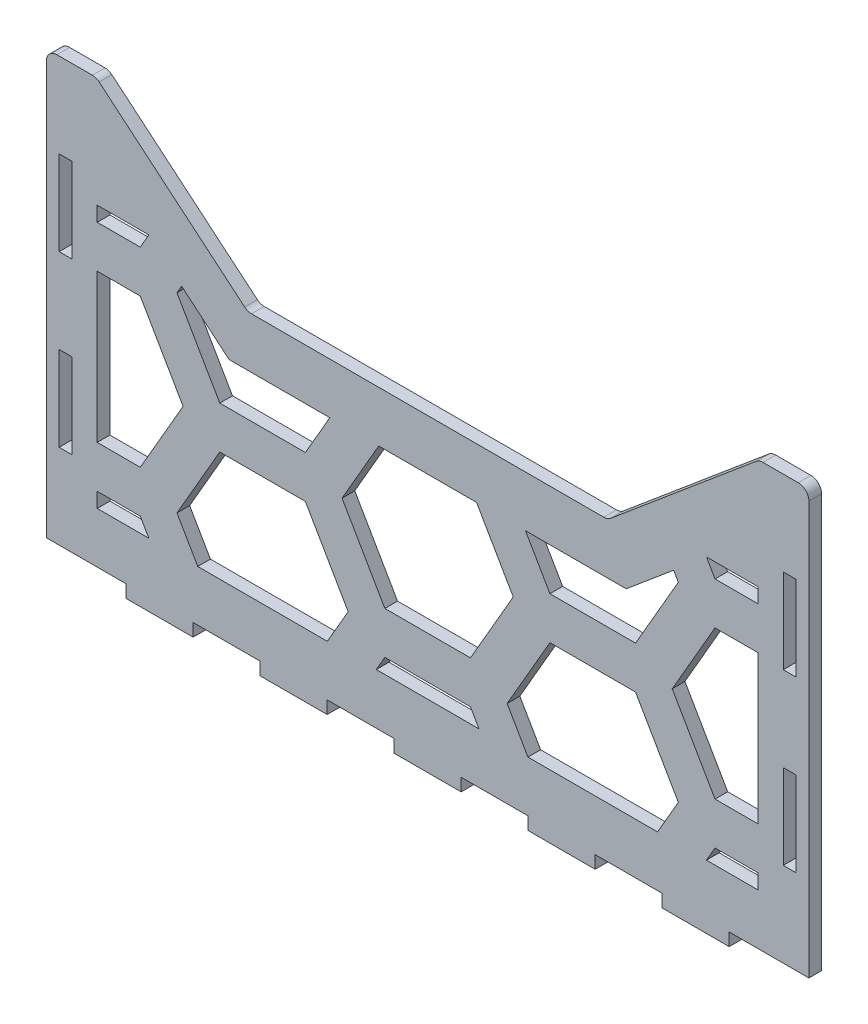
from build123d import *

# Parameters (mm, degrees)
SKETCH1_W               = 3.05
SKETCH1_H               = 20
SKETCH1_W_2             = 15.818181818
SKETCH1_H_2             = 3
BOSS_EXTRUDE1_DEPTH     = 3
CUT_EXTRUDE9_DEPTH      = 1
CUT_EXTRUDE9_DEPTH_BACK = 4
FILLET3_R               = 2.5
CUT_EXTRUDE8_DEPTH      = 4
CUT_EXTRUDE8_DEPTH_BACK = 1


with BuildPart() as part:
    # Sketch1 → Boss-Extrude1 (new body)
    with BuildSketch(Plane.XY):
        Polygon((-90, 50), (-90, -50), (-71.181818182, -50), (-55.363636364, -50), (-39.545454545, -50), (-23.727272727, -50), (-7.909090909, -50), (7.909090909, -50), (23.727272727, -50), (39.545454545, -50), (55.363636364, -50), (71.181818182, -50), (90, -50), (90, 50), align=None)
        with Locations((-85.475, -20)):
            Rectangle(SKETCH1_W, SKETCH1_H, mode=Mode.SUBTRACT)
        with Locations((85.475, -20)):
            Rectangle(SKETCH1_W, SKETCH1_H, mode=Mode.SUBTRACT)
        with Locations((-85.475, 20)):
            Rectangle(SKETCH1_W, SKETCH1_H, mode=Mode.SUBTRACT)
        with Locations((85.475, 20)):
            Rectangle(SKETCH1_W, SKETCH1_H, mode=Mode.SUBTRACT)
        with Locations((-63.272727273, -51.5)):
            Rectangle(SKETCH1_W_2, SKETCH1_H_2)
        with Locations((-31.636363636, -51.5)):
            Rectangle(SKETCH1_W_2, SKETCH1_H_2)
        with Locations((0, -51.5)):
            Rectangle(SKETCH1_W_2, SKETCH1_H_2)
        with Locations((31.636363636, -51.5)):
            Rectangle(SKETCH1_W_2, SKETCH1_H_2)
        with Locations((63.272727273, -51.5)):
            Rectangle(SKETCH1_W_2, SKETCH1_H_2)
    extrude(amount=BOSS_EXTRUDE1_DEPTH)

    # Sketch7 → Cut-Extrude9 (cut, two sides)
    with BuildSketch(Plane.XY.offset(3)) as cut_extrude9_sk:
        Polygon((-78.252607778, 50), (-42.5, 20), (42.5, 20), (78.252607778, 50), align=None)
    extrude(amount=CUT_EXTRUDE9_DEPTH, mode=Mode.SUBTRACT)
    extrude(cut_extrude9_sk.sketch, amount=-CUT_EXTRUDE9_DEPTH_BACK, mode=Mode.SUBTRACT)

    # Fillet3
    fillet3_edges = [part.edges().sort_by_distance(p)[0] for p in [
        (-78.252607778, 50, 1.5),
        (78.252607778, 50, 1.5),
        (42.5, 20, 1.5),
        (-42.5, 20, 1.5),
        (-90, 50, 1.5),
        (90, 50, 1.5),
    ]]
    fillet(fillet3_edges, radius=FILLET3_R)

    # Sketch6 → Cut-Extrude8 (cut, two sides)
    with BuildSketch(Plane.XY) as cut_extrude8_sk:
        Polygon((-67.83865663, 10.5), (-78, 10.5), (-78, -24.5), (-67.83865663, -24.5), (-57.735026919, -7), align=None)
        Polygon((-59.178402592, -29.5), (-54.270925304, -38), (-23.671361037, -38), (-18.763883749, -29.5), (-28.867513459, -12), (-49.074772881, -12), align=None)
        Polygon((-67.83865663, -34.5), (-78, -34.5), (-78, -38), (-65.817930688, -38), align=None)
        Polygon((-10.103629711, -34.5), (-12.124355653, -38), (12.124355653, -38), (10.103629711, -34.5), align=None)
        Polygon((18.763883749, -29.5), (23.671361037, -38), (54.270925304, -38), (59.178402592, -29.5), (49.074772881, -12), (28.867513459, -12), align=None)
        Polygon((78, -38), (78, -34.5), (67.83865663, -34.5), (65.817930688, -38), align=None)
        Polygon((78, -24.5), (78, 10.5), (67.83865663, 10.5), (57.735026919, -7), (67.83865663, -24.5), align=None)
        Polygon((11.547005384, 8), (-11.547005384, 8), (-20.207259422, -7), (-10.103629711, -24.5), (10.103629711, -24.5), (20.207259422, -7), align=None)
        Polygon((-46.867642811, 8), (-58.077745879, 17.406393349), (-59.178402592, 15.5), (-49.074772881, -2), (-28.867513459, -2), (-23.094010768, 8), align=None)
        Polygon((46.867642811, 8), (23.094010768, 8), (28.867513459, -2), (49.074772881, -2), (59.178402592, 15.5), (58.077745879, 17.406393349), align=None)
        Polygon((-67.83865663, 20.5), (-65.856365013, 23.933429796), (-65.935700293, 24), (-78, 24), (-78, 20.5), align=None)
        Polygon((65.935700293, 24), (65.856365013, 23.933429796), (67.83865663, 20.5), (78, 20.5), (78, 24), align=None)
    extrude(amount=CUT_EXTRUDE8_DEPTH, mode=Mode.SUBTRACT)
    extrude(cut_extrude8_sk.sketch, amount=-CUT_EXTRUDE8_DEPTH_BACK, mode=Mode.SUBTRACT)


solid = part.part
